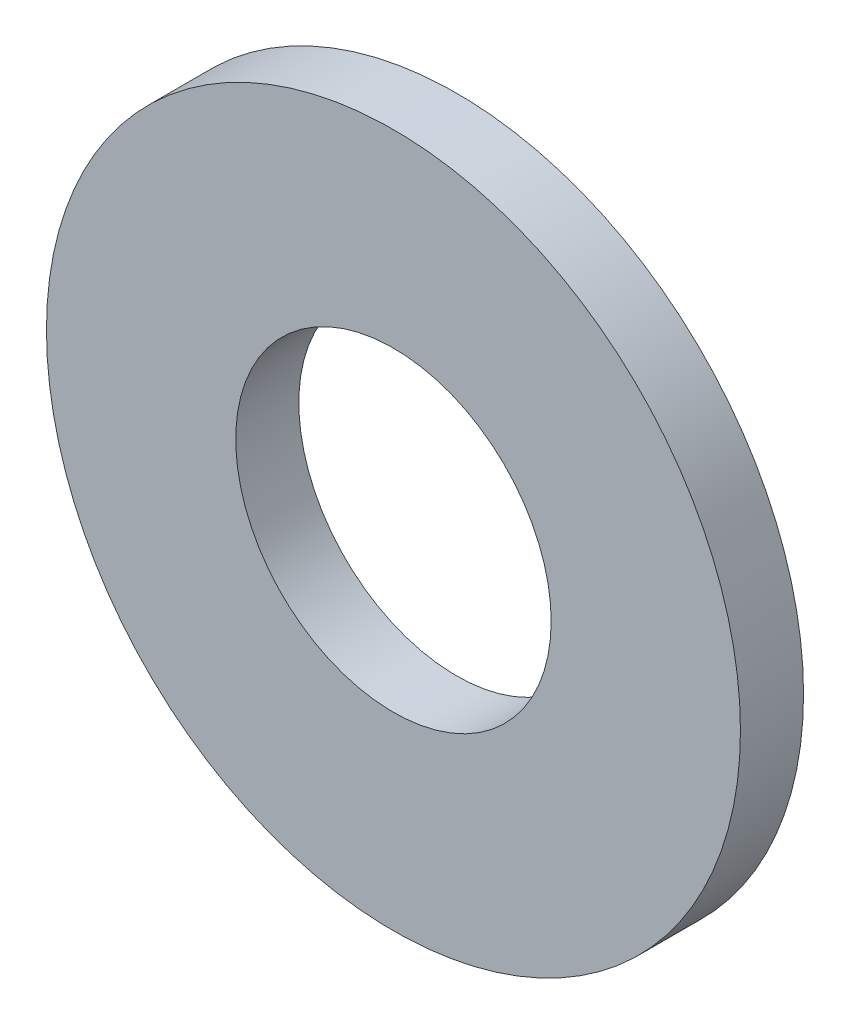
from build123d import *

# Parameters (mm, degrees)
SKETCH1_R           = 11
SKETCH1_R_2         = 5
BOSS_EXTRUDE1_DEPTH = 2


with BuildPart() as part:
    # Sketch1 → Boss-Extrude1 (new body)
    with BuildSketch(Plane.XY):
        Circle(SKETCH1_R)
        Circle(SKETCH1_R_2, mode=Mode.SUBTRACT)
    extrude(amount=BOSS_EXTRUDE1_DEPTH)


solid = part.part
